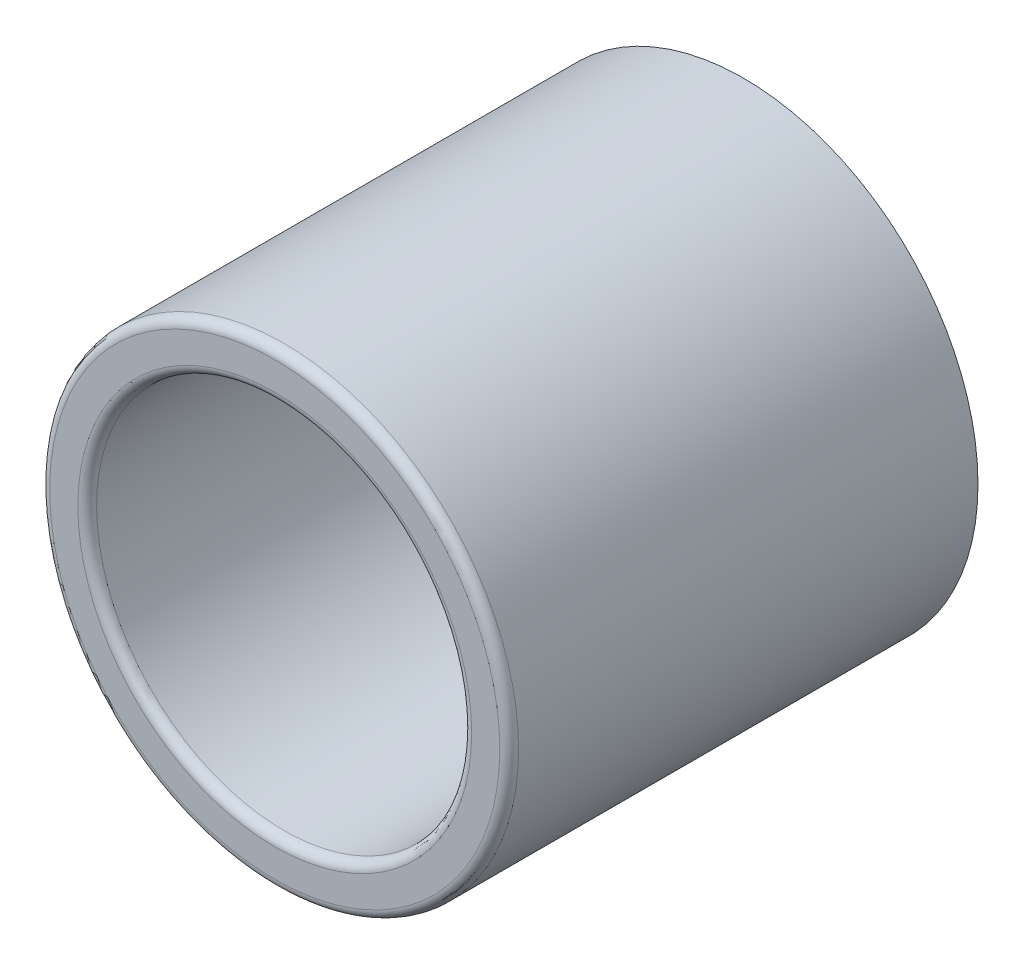
from build123d import *

# Parameters (mm, degrees)
SKETCH1_R           = 2.5
SKETCH1_R_2         = 2
BOSS_EXTRUDE1_DEPTH = 5
FILLET1_R           = 0.1


with BuildPart() as part:
    # Sketch1 → Boss-Extrude1 (new body)
    with BuildSketch(Plane.XY):
        Circle(SKETCH1_R)
        Circle(SKETCH1_R_2, mode=Mode.SUBTRACT)
    extrude(amount=BOSS_EXTRUDE1_DEPTH)

    # Fillet1
    fillet1_edges = [part.edges().sort_by_distance(p)[0] for p in [
        (-2.5, 0, 5),
        (-2, 0, 5),
    ]]
    fillet(fillet1_edges, radius=FILLET1_R)


solid = part.part
